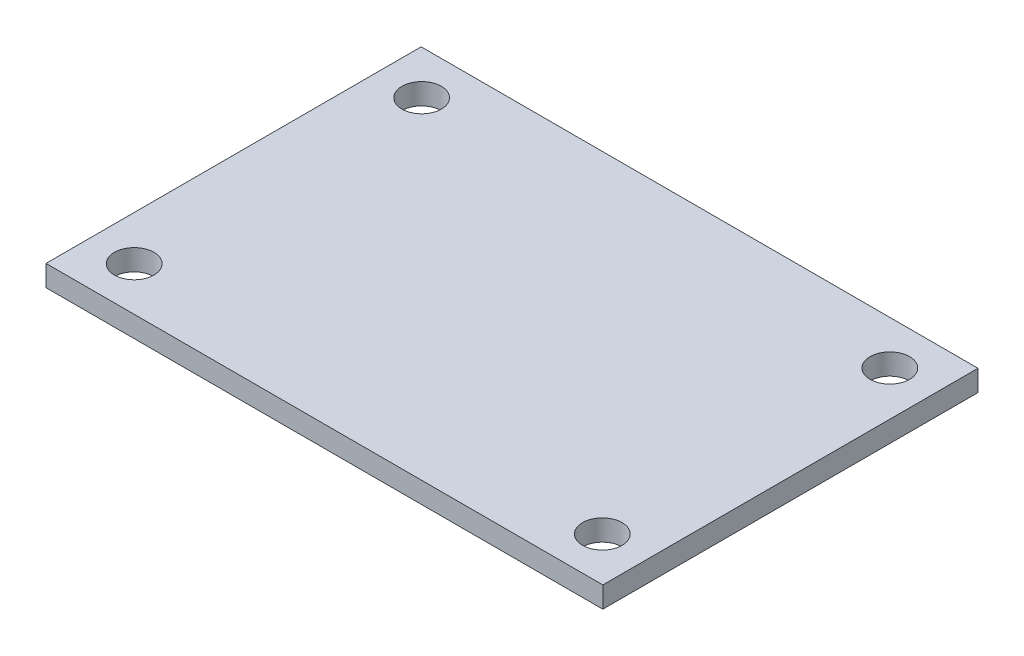
from build123d import *

# Parameters (mm, degrees)
SKETCH1_W           = 42.3
SKETCH1_H           = 28.5
SKETCH1_R           = 1.5
BOSS_EXTRUDE1_DEPTH = 1.6


with BuildPart() as part:
    # Sketch1 → Boss-Extrude1 (new body)
    with BuildSketch(Plane(origin=(0, 0, 0), x_dir=(1, 0, 0), z_dir=(0, 1, 0))):
        Rectangle(SKETCH1_W, SKETCH1_H)
        with Locations((-17.7817, 10.9198)):
            Circle(SKETCH1_R, mode=Mode.SUBTRACT)
        with Locations((17.7817, 10.9198)):
            Circle(SKETCH1_R, mode=Mode.SUBTRACT)
        with Locations((17.7817, -10.9198)):
            Circle(SKETCH1_R, mode=Mode.SUBTRACT)
        with Locations((-17.7817, -10.9198)):
            Circle(SKETCH1_R, mode=Mode.SUBTRACT)
    extrude(amount=BOSS_EXTRUDE1_DEPTH)


solid = part.part
